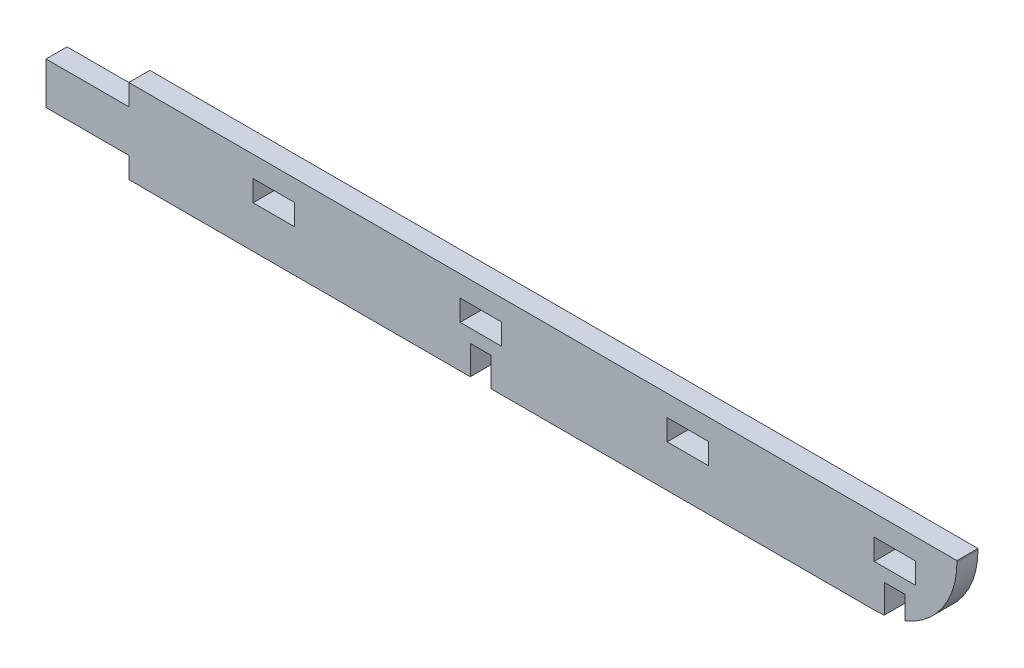
from build123d import *

# Parameters (mm, degrees)
BOSS_EXTRUDE1_DEPTH = 5.08
FILLET1_R           = 20
SKETCH2_W           = 5
SKETCH2_H           = 7
SKETCH2_W_2         = 10
SKETCH2_H_2         = 5.08
CUT_EXTRUDE1_DEPTH  = 6.08


with BuildPart() as part:
    # Sketch1 → Boss-Extrude1 (new body)
    with BuildSketch(Plane.XY):
        Polygon((-100, 5.08), (-100, 10.16), (100, 10.16), (100, -10.16), (-100, -10.16), (-100, -5.08), (-120, -5.08), (-120, 5.08), align=None)
    extrude(amount=BOSS_EXTRUDE1_DEPTH)

    # Fillet1
    fillet1_edges = [part.edges().sort_by_distance(p)[0] for p in [
        (100, -10.16, 2.54),
    ]]
    fillet(fillet1_edges, radius=FILLET1_R)

    # Sketch2 → Cut-Extrude1 (cut, through all)
    with BuildSketch(Plane.XY.offset(5.08)):
        with Locations((-15.04, -6.66)):
            Rectangle(SKETCH2_W, SKETCH2_H)
        with Locations((84.96, -6.66)):
            Rectangle(SKETCH2_W, SKETCH2_H)
        with Locations((-65, 2.54)):
            Rectangle(SKETCH2_W_2, SKETCH2_H_2)
        with Locations((-15, 2.54)):
            Rectangle(SKETCH2_W_2, SKETCH2_H_2)
        with Locations((35, 2.54)):
            Rectangle(SKETCH2_W_2, SKETCH2_H_2)
        with Locations((85, 2.54)):
            Rectangle(SKETCH2_W_2, SKETCH2_H_2)
    extrude(amount=-CUT_EXTRUDE1_DEPTH, mode=Mode.SUBTRACT)


solid = part.part
